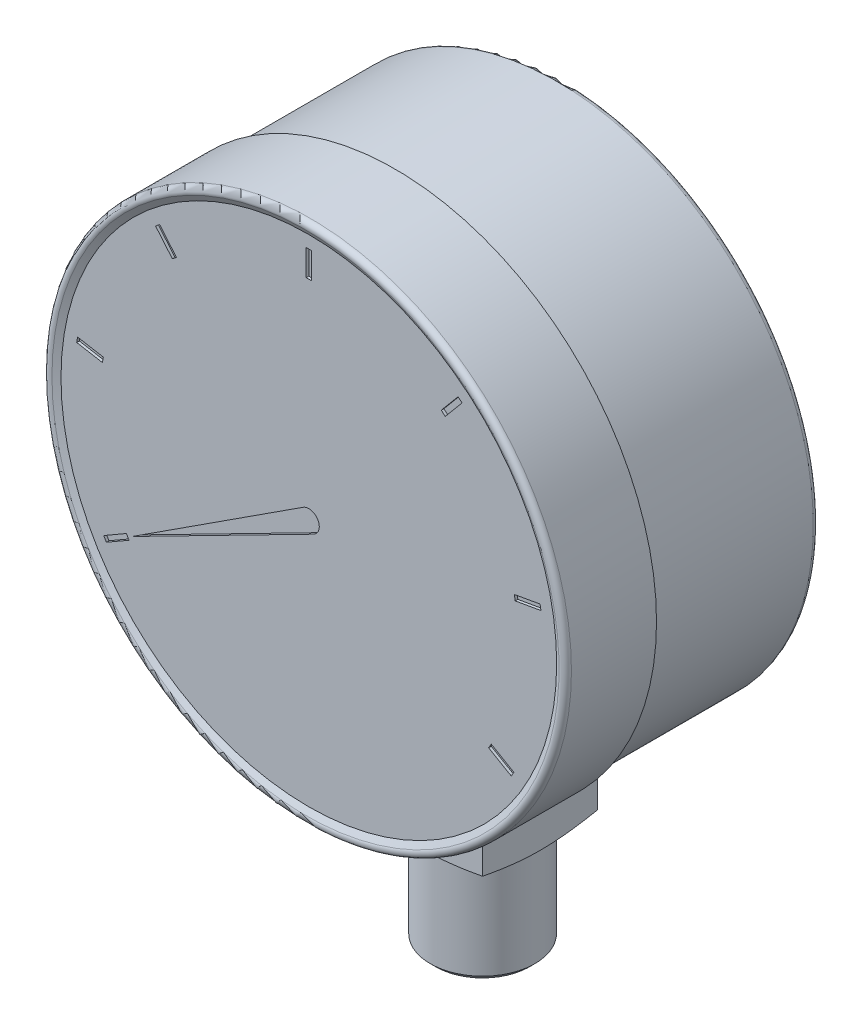
from build123d import *

# Parameters (mm, degrees)
ZAOBLIT1_R               = 1
SKICA2_W                 = 1
SKICA2_H                 = 5
ODEBRAT_VYSUNUT_M1_DEPTH = 0.5
KRUHOV_POLE1_COUNT       = 9
ODEBRAT_VYSUNUT_M2_DEPTH = 0.5
SKICA4_W                 = 22
SKICA4_H                 = 22
P_IDAT_VYSUNUT_M1_DEPTH  = 89
ZKOSEN_1_SIZE            = 1


with BuildPart() as part:
    # Skica1 → Rotovat1 (revolve)
    with BuildSketch(Plane(origin=(0, 0, 0), x_dir=(0, 0, -1), z_dir=(1, 0, 0)), mode=Mode.PRIVATE) as rotovat1_sk:
        Polygon((0, 50), (1.5, 47.401923789), (1.5, 0), (50, 0), (50, 49), (18, 49), (18, 50), align=None)
    revolve(rotovat1_sk.sketch.rotate(Axis((0, 0, 0), (0, 0, 1)), 90), axis=Axis((0, 0, 0), (0, 0, 1)))  # turned: the seam where the file's is

    # Zaoblit1
    zaoblit1_edges = [part.edges().sort_by_distance(p)[0] for p in [
        (50, 0, 0),
        (49, 0, -50),
    ]]
    fillet(zaoblit1_edges, radius=ZAOBLIT1_R)

    # Skica2 → Odebrat vysunutím1 (cut)
    with BuildSketch(Plane.XY.offset(-1.5)):
        with Locations((0, 42.5)):
            Rectangle(SKICA2_W, SKICA2_H)
    odebrat_vysunut_m1 = extrude(amount=-ODEBRAT_VYSUNUT_M1_DEPTH, mode=Mode.SUBTRACT)

    # Kruhové pole1: Odebrat vysunutím1 ×9 about axis, 2 skipped
    kruhov_pole1_axis = Axis((0, 0, 0), (0, 0, -1))
    add([odebrat_vysunut_m1.rotate(kruhov_pole1_axis, i * 360 / KRUHOV_POLE1_COUNT) for i in range(1, KRUHOV_POLE1_COUNT) if i not in (4, 5)], mode=Mode.SUBTRACT)

    # Skica3 → Odebrat vysunutím2 (cut)
    with BuildSketch(Plane.XY.offset(-1.5)):
        with BuildLine():
            Line((-1.087507328, 1.678489741), (-33.774990748, -19.5))
            Line((-33.774990748, -19.5), (0.909861092, -1.781053844))
            ThreePointArc((0.909861092, -1.781053844), (1.732050808, 1), (-1.087507328, 1.678489741))
        make_face()
    extrude(amount=-ODEBRAT_VYSUNUT_M2_DEPTH, mode=Mode.SUBTRACT)

    # Skica4 → Přidat vysunutím1 (add)
    with BuildSketch(Plane(origin=(0, 0, 0), x_dir=(1, 0, 0), z_dir=(0, 1, 0))):
        with Locations((0, 34.732050808)):
            Rectangle(SKICA4_W, SKICA4_H)
    extrude(amount=-P_IDAT_VYSUNUT_M1_DEPTH)

    # Skica5 → Odebrat rotací1 (revolve, cut)
    with BuildSketch(Plane(origin=(0, 0, 0), x_dir=(0, 0, -1), z_dir=(1, 0, 0)), mode=Mode.PRIVATE) as odebrat_rotac_1_sk:
        Polygon((3.732050808, -60.373066959), (24.732050808, -66), (24.732050808, -86), (32.232050808, -86), (32.232050808, -89), (3.732050808, -89), align=None)
    revolve(odebrat_rotac_1_sk.sketch.rotate(Axis((0, -89, -34.732050808), (0, 1, 0)), 180), axis=Axis((0, -89, -34.732050808), (0, 1, 0)), mode=Mode.SUBTRACT)  # turned: the seam where the file's is

    # Zkosení1
    zkosen_1_edges = [part.edges().sort_by_distance(p)[0] for p in [
        (0, -86, -24.732050808),
    ]]
    chamfer(zkosen_1_edges, length=ZKOSEN_1_SIZE)


solid = part.part
